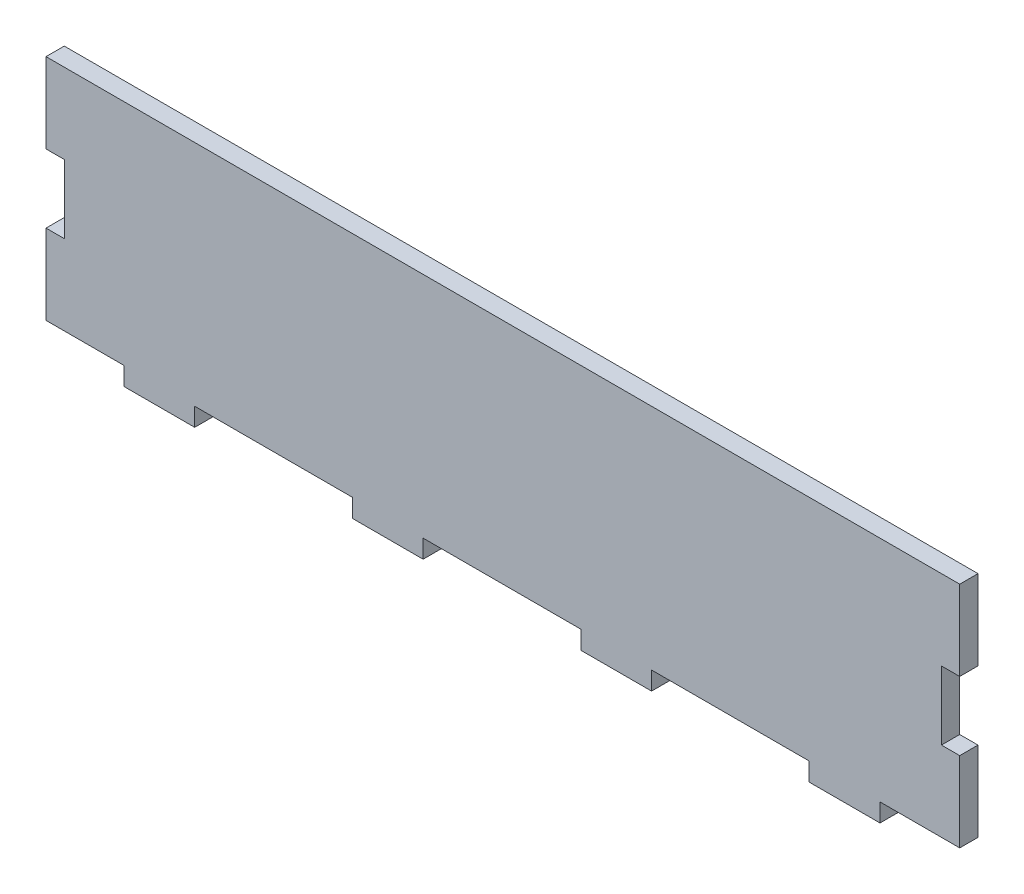
from build123d import *

# Parameters (mm, degrees)
SKIZZE1_W                       = 200
SKIZZE1_H                       = 50
AUFSATZ_LINEAR_AUSTRAGEN1_DEPTH = 4
SKIZZE2_W                       = 15.5
SKIZZE2_H                       = 4
AUFSATZ_LINEAR_AUSTRAGEN2_DEPTH = 4
SCHNITT_LINEAR_AUSTRAGEN1_REACH = 6
SKIZZE4_W                       = 4
SKIZZE4_H                       = 15


with BuildPart() as part:
    # Skizze1 → Aufsatz-Linear austragen1 (new body)
    with BuildSketch(Plane.XY):
        with Locations((100, 25)):
            Rectangle(SKIZZE1_W, SKIZZE1_H)
    extrude(amount=AUFSATZ_LINEAR_AUSTRAGEN1_DEPTH)

    # Skizze2 → Aufsatz-Linear austragen2 (add)
    with BuildSketch(Plane(origin=(0, 0, 4), x_dir=(-1, 0, 0), z_dir=(0, 0, -1))):
        with Locations((-174.8, -2)):
            Rectangle(SKIZZE2_W, SKIZZE2_H)
        with Locations((-124.8, -2)):
            Rectangle(SKIZZE2_W, SKIZZE2_H)
        with Locations((-74.8, -2)):
            Rectangle(SKIZZE2_W, SKIZZE2_H)
        with Locations((-24.8, -2)):
            Rectangle(SKIZZE2_W, SKIZZE2_H)
    extrude(amount=AUFSATZ_LINEAR_AUSTRAGEN2_DEPTH)

    # Skizze4 → Schnitt-Linear austragen1 (cut, up to next)
    with BuildSketch(Plane.XY.offset(4), mode=Mode.PRIVATE) as schnitt_linear_austragen1_sk1:
        with Locations((2, 25)):
            Rectangle(SKIZZE4_W, SKIZZE4_H)
    schnitt_linear_austragen1_tool1 = extrude(schnitt_linear_austragen1_sk1.sketch, amount=-SCHNITT_LINEAR_AUSTRAGEN1_REACH, mode=Mode.PRIVATE) & part.part
    add(schnitt_linear_austragen1_tool1.solids().sort_by_distance((2, 25, 4))[0], mode=Mode.SUBTRACT)
    # Skizze4 → Schnitt-Linear austragen1 (cut, up to next)
    with BuildSketch(Plane.XY.offset(4), mode=Mode.PRIVATE) as schnitt_linear_austragen1_sk2:
        with Locations((198, 25)):
            Rectangle(SKIZZE4_W, SKIZZE4_H)
    schnitt_linear_austragen1_tool2 = extrude(schnitt_linear_austragen1_sk2.sketch, amount=-SCHNITT_LINEAR_AUSTRAGEN1_REACH, mode=Mode.PRIVATE) & part.part
    add(schnitt_linear_austragen1_tool2.solids().sort_by_distance((198, 25, 4))[0], mode=Mode.SUBTRACT)


solid = part.part
